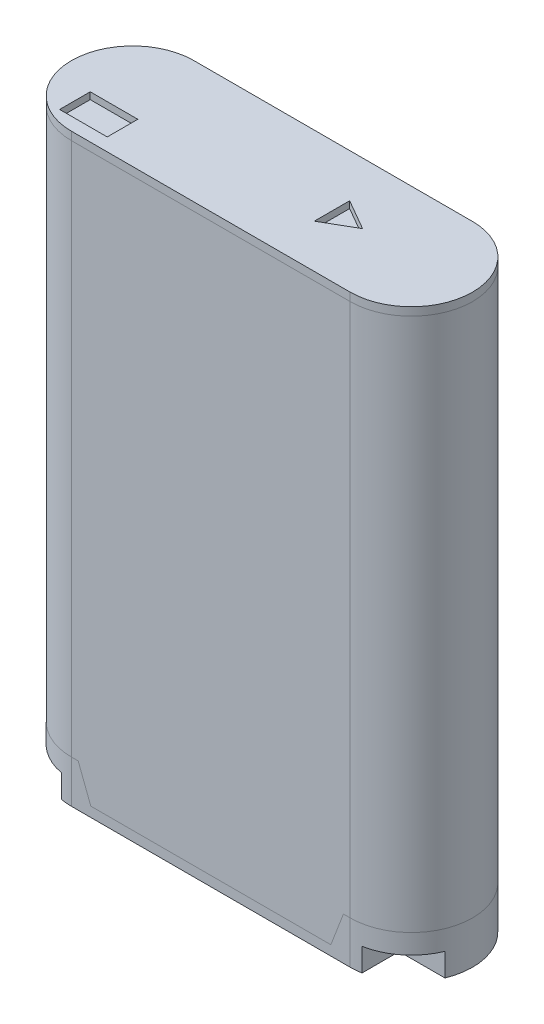
from build123d import *

# Parameters (mm, degrees)
BOSS_EXTRUDE1_DEPTH = 43
SKETCH2_W           = 3.5
SKETCH2_H           = 2.25
CUT_EXTRUDE1_DEPTH  = 0.5
SKETCH3_W           = 4.15
SKETCH3_H           = 3.2
SKETCH3_W_2         = 3
CUT_EXTRUDE2_DEPTH  = 0.75
SKETCH5_R           = 1.25
CUT_EXTRUDE3_DEPTH  = 0.25
SKETCH6_W           = 1.326960347
SKETCH6_H           = 0.484850896
BOSS_EXTRUDE2_DEPTH = 0.25
SKETCH7_W           = 3.7
SKETCH7_H           = 2.8
CUT_EXTRUDE4_DEPTH  = 1.7


with BuildPart() as part:
    # Sketch1 → Boss-Extrude1 (new body)
    with BuildSketch(Plane(origin=(0, 0, 0), x_dir=(1, 0, 0), z_dir=(0, 1, 0))):
        with BuildLine():
            Line((-10.25, 4.5), (10.25, 4.5))
            ThreePointArc((10.25, 4.5), (14.75, 0), (10.25, -4.5))
            Line((10.25, -4.5), (-10.25, -4.5))
            ThreePointArc((-10.25, -4.5), (-14.75, 0), (-10.25, 4.5))
        make_face()
    extrude(amount=BOSS_EXTRUDE1_DEPTH)

    # Sketch2 → Cut-Extrude1 (cut)
    with BuildSketch(Plane(origin=(0, 43, 0), x_dir=(1, 0, 0), z_dir=(0, 1, 0))):
        with Locations((-10.319273123, -2.424555182)):
            Rectangle(SKETCH2_W, SKETCH2_H)
        Polygon((6.661858634, 0), (4.410192585, 1.3), (4.410192585, -1.3), align=None)
    extrude(amount=-CUT_EXTRUDE1_DEPTH, mode=Mode.SUBTRACT)

    # Sketch3 → Cut-Extrude2 (cut)
    with BuildSketch(Plane.XZ):
        with Locations((-9.075, -1.6)):
            Rectangle(SKETCH3_W, SKETCH3_H)
        with Locations((-4.2, -1.6)):
            Rectangle(SKETCH3_W_2, SKETCH3_H)
        with Locations((0.775, -1.6)):
            Rectangle(SKETCH3_W, SKETCH3_H)
        with Locations((5.35, -1.6)):
            Rectangle(SKETCH3_W_2, SKETCH3_H)
    extrude(amount=-CUT_EXTRUDE2_DEPTH, mode=Mode.SUBTRACT)

    # Sketch5 → Cut-Extrude3 (cut)
    with BuildSketch(Plane.XZ):
        with Locations((-9.075, 2.25)):
            Circle(SKETCH5_R)
        with Locations((-4.2, 2.25)):
            Circle(SKETCH5_R)
        with Locations((0.775, 2.25)):
            Circle(SKETCH5_R)
        with Locations((5.35, 2.25)):
            Circle(SKETCH5_R)
    extrude(amount=-CUT_EXTRUDE3_DEPTH, mode=Mode.SUBTRACT)

    # Sketch6 → Boss-Extrude2 (add)
    with BuildSketch(Plane.XZ.offset(-0.25)):
        Polygon((-9.319136071, 2.080501294), (-9.924638911, 2.080501294), (-9.924638911, 2.512434892), (-9.319136071, 2.512434892), (-9.319136071, 3.219423302), (-8.814550371, 3.219423302), (-8.814550371, 2.512434892), (-8.194630797, 2.512434892), (-8.194630797, 2.080501294), (-8.814550371, 2.080501294), (-8.814550371, 1.323622745), (-9.319136071, 1.323622745), align=None)
        with Locations((0.807600037, 2.270009444)):
            Rectangle(SKETCH6_W, SKETCH6_H)
        with BuildLine():
            Line((4.715564351, 1.80853907), (4.912980216, 1.997240994))
            add(Edge.make_bspline(
                [(4.912980216, 1.997240994), (4.929707146, 1.979899926), (4.962433267, 1.945972249), (5.015418116, 1.901557226), (5.069888716, 1.863810031), (5.125997527, 1.833043383), (5.183712319, 1.808626724), (5.243133504, 1.791593673), (5.30411755, 1.780868656), (5.345327837, 1.77968748), (5.366105216, 1.779091955)],
                knots=[0, 0, 0, 0, 7.224e-05, 0.000141338, 0.000207016, 0.000270758, 0.000332981, 0.000394603, 0.000455858, 0.000518145, 0.000518145, 0.000518145, 0.000518145], degree=3))
            add(Edge.make_bspline(
                [(5.366105216, 1.779091955), (5.383454547, 1.779571665), (5.417691539, 1.78051832), (5.467955666, 1.787474955), (5.516054131, 1.799260394), (5.562025094, 1.815642069), (5.60609584, 1.836272091), (5.647855993, 1.862202541), (5.687529977, 1.892567959), (5.724654232, 1.927315209), (5.758169405, 1.965560051), (5.788367052, 2.005838724), (5.813379552, 2.048863663), (5.833797229, 2.09400743), (5.849886827, 2.141286329), (5.86130626, 2.190697991), (5.867922688, 2.24235398), (5.868909154, 2.277470612), (5.869410505, 2.295317917)],
                knots=[0, 0, 0, 0, 5.2039e-05, 0.000102693, 0.000151885, 0.000200355, 0.000248878, 0.000297579, 0.000347521, 0.000398543, 0.000449848, 0.000499909, 0.000549331, 0.000598819, 0.000648325, 0.000698909, 0.000750715, 0.000804255, 0.000804255, 0.000804255, 0.000804255], degree=3))
            add(Edge.make_bspline(
                [(5.869410505, 2.295317917), (5.869263959, 2.307844037), (5.868975113, 2.332533276), (5.86589296, 2.368961679), (5.860774249, 2.404382271), (5.853594852, 2.438690106), (5.844556603, 2.472033181), (5.833494646, 2.504194313), (5.820119677, 2.535214768), (5.805150865, 2.565257037), (5.788442474, 2.594066561), (5.769713133, 2.621261294), (5.74917272, 2.646629922), (5.727643129, 2.671055186), (5.703698503, 2.693107682), (5.678410927, 2.714002754), (5.651417573, 2.733222757), (5.622751223, 2.750500219), (5.593267533, 2.766602513), (5.562362337, 2.779937286), (5.530899248, 2.791924454), (5.498326297, 2.800942411), (5.465217256, 2.808786127), (5.431111276, 2.813576528), (5.396332037, 2.8172166), (5.372826074, 2.817440712), (5.360997043, 2.817553494)],
                knots=[0, 0, 0, 0, 3.7571e-05, 7.4053e-05, 0.000109578, 0.000144878, 0.000179138, 0.000213158, 0.000246813, 0.000280408, 0.000313803, 0.000346642, 0.00037935, 0.000411691, 0.000444216, 0.00047688, 0.000510064, 0.000543509, 0.000577252, 0.000610751, 0.000644407, 0.00067817, 0.000712066, 0.000746402, 0.000781414, 0.000816882, 0.000816882, 0.000816882, 0.000816882], degree=3))
            add(Edge.make_bspline(
                [(5.360997043, 2.817553494), (5.340932624, 2.81697445), (5.301511258, 2.81583678), (5.24366326, 2.806901525), (5.188381183, 2.792269684), (5.144297695, 2.774670447), (5.109804461, 2.757561474), (5.083558758, 2.7419627), (5.056533291, 2.724293685), (5.028913098, 2.70406497), (5.000548666, 2.681517285), (4.971927273, 2.656179356), (4.94232014, 2.628879026), (4.922924645, 2.609394521), (4.912980216, 2.599404455)],
                knots=[0, 0, 0, 0, 6.0171e-05, 0.000118221, 0.000175146, 0.00023139, 0.000260282, 0.000290584, 0.000322921, 0.000357119, 0.000393253, 0.000431582, 0.000471767, 0.00051405, 0.00051405, 0.00051405, 0.00051405], degree=3))
            Line((4.912980216, 2.599404455), (4.721573966, 2.80042609))
            add(Edge.make_bspline(
                [(4.721573966, 2.80042609), (4.735028795, 2.813416305), (4.761289744, 2.838770428), (4.800903659, 2.874770908), (4.840467708, 2.907121373), (4.879026152, 2.936995856), (4.917210456, 2.963524548), (4.955017137, 2.98673217), (4.992016231, 3.00721189), (5.028982989, 3.024596757), (5.066210855, 3.039452525), (5.104498273, 3.051981146), (5.143863537, 3.062917773), (5.184632673, 3.071524335), (5.226623771, 3.078530672), (5.269971765, 3.083160305), (5.314474118, 3.086370664), (5.344564827, 3.086645271), (5.35979512, 3.086784263)],
                knots=[0, 0, 0, 0, 5.6107e-05, 0.000109509, 0.000160524, 0.000209386, 0.000255813, 0.000299927, 0.000342421, 0.000382612, 0.000422396, 0.000462589, 0.000503412, 0.000544902, 0.000587533, 0.000631069, 0.000675641, 0.000721323, 0.000721323, 0.000721323, 0.000721323], degree=3))
            add(Edge.make_bspline(
                [(5.35979512, 3.086784263), (5.387770205, 3.086069862), (5.44250967, 3.084671977), (5.522736662, 3.074350257), (5.599013379, 3.056931828), (5.671476881, 3.03263203), (5.739905397, 3.001078873), (5.804513521, 2.962792741), (5.865193661, 2.917410259), (5.921423669, 2.865607584), (5.972270451, 2.808383842), (6.017263923, 2.746964786), (6.05431883, 2.680909351), (6.085758013, 2.611632486), (6.109316906, 2.538051127), (6.126465703, 2.460830166), (6.136900657, 2.379638221), (6.138053378, 2.324195186), (6.138641274, 2.295918878)],
                knots=[0, 0, 0, 0, 8.3912e-05, 0.000164192, 0.000242185, 0.000318297, 0.000393051, 0.000467825, 0.000543186, 0.000619954, 0.000696787, 0.000772517, 0.000847877, 0.000923602, 0.00100038, 0.001079187, 0.001160659, 0.001245459, 0.001245459, 0.001245459, 0.001245459], degree=3))
            add(Edge.make_bspline(
                [(6.138641274, 2.295918878), (6.138384513, 2.277478096), (6.137875675, 2.240932973), (6.132859378, 2.186959442), (6.12516416, 2.134563275), (6.114212057, 2.083808916), (6.100594572, 2.034520629), (6.083261482, 1.986921578), (6.063185313, 1.940751187), (6.039746603, 1.896439727), (6.013473059, 1.853931201), (5.984748971, 1.813333056), (5.953021206, 1.775049105), (5.918591266, 1.738911903), (5.881745297, 1.704687885), (5.842122948, 1.672619943), (5.799686332, 1.642914873), (5.754868318, 1.615548264), (5.708522141, 1.590415811), (5.660614863, 1.569342312), (5.612080106, 1.550739522), (5.56258902, 1.535713643), (5.512032672, 1.524379585), (5.460797123, 1.51582654), (5.408463744, 1.51103959), (5.373325792, 1.51025649), (5.355588389, 1.509861186)],
                knots=[0, 0, 0, 0, 5.5309e-05, 0.000109609, 0.000162473, 0.0002141, 0.00026528, 0.000315751, 0.000365939, 0.000416209, 0.000465993, 0.000515768, 0.000565283, 0.000615018, 0.00066541, 0.000716045, 0.000767813, 0.000820688, 0.000873519, 0.000925843, 0.000977576, 0.001029382, 0.001080845, 0.001132911, 0.001185116, 0.001238332, 0.001238332, 0.001238332, 0.001238332], degree=3))
            add(Edge.make_bspline(
                [(5.355588389, 1.509861186), (5.340456681, 1.510088069), (5.310350592, 1.510539475), (5.265516337, 1.514295789), (5.221045554, 1.52021179), (5.177074042, 1.529075404), (5.133404064, 1.539809648), (5.090218454, 1.553031339), (5.047636298, 1.569158702), (5.005288443, 1.58699897), (4.964019452, 1.607309189), (4.924187982, 1.630042499), (4.885695338, 1.654604176), (4.848773565, 1.681416683), (4.813162609, 1.71008618), (4.778900466, 1.740611719), (4.746315906, 1.773547024), (4.72586669, 1.796816088), (4.715564351, 1.80853907)],
                knots=[0, 0, 0, 0, 4.5389e-05, 9.0305e-05, 0.000134883, 0.000179905, 0.000224797, 0.000269754, 0.000315297, 0.000361342, 0.000407569, 0.000453187, 0.000498865, 0.000544484, 0.000590004, 0.000635969, 0.000682075, 0.000728889, 0.000728889, 0.000728889, 0.000728889], degree=3))
        make_face()
        Polygon((-3.830473477, 1.548322724), (-4.638165785, 1.548322724), (-4.638165785, 1.817553494), (-4.368935016, 1.817553494), (-4.368935016, 3.048322724), (-4.099704247, 3.048322724), (-4.099704247, 1.817553494), (-3.830473477, 1.817553494), align=None)
    extrude(amount=BOSS_EXTRUDE2_DEPTH)

    # Sketch7 → Cut-Extrude4 (cut)
    with BuildSketch(Plane.XZ):
        with Locations((-12.9, 3.1)):
            Rectangle(SKETCH7_W, SKETCH7_H)
        with Locations((12.9, 3.1)):
            Rectangle(SKETCH7_W, SKETCH7_H)
    extrude(amount=-CUT_EXTRUDE4_DEPTH, mode=Mode.SUBTRACT)


solid = part.part
